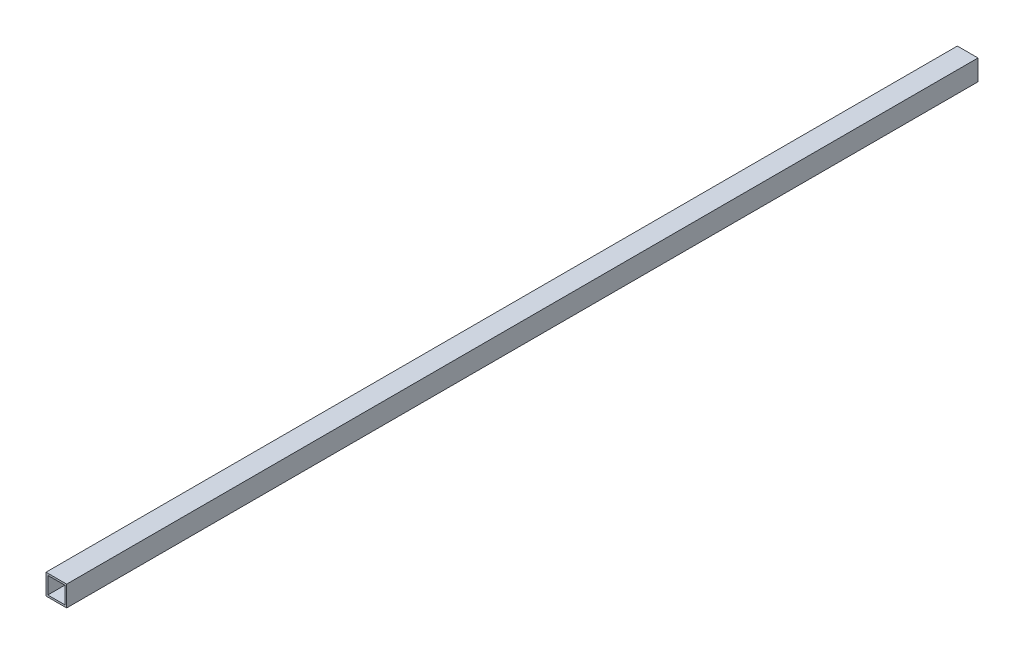
from build123d import *

# Parameters (mm, degrees)
SKETCH1_W           = 17
SKETCH1_H           = 17
SKETCH1_W_2         = 14
SKETCH1_H_2         = 14
BOSS_EXTRUDE1_DEPTH = 750


with BuildPart() as part:
    # Sketch1 → Boss-Extrude1 (new body)
    with BuildSketch(Plane.XY):
        Rectangle(SKETCH1_W, SKETCH1_H)
        Rectangle(SKETCH1_W_2, SKETCH1_H_2, mode=Mode.SUBTRACT)
    extrude(amount=BOSS_EXTRUDE1_DEPTH)


solid = part.part
